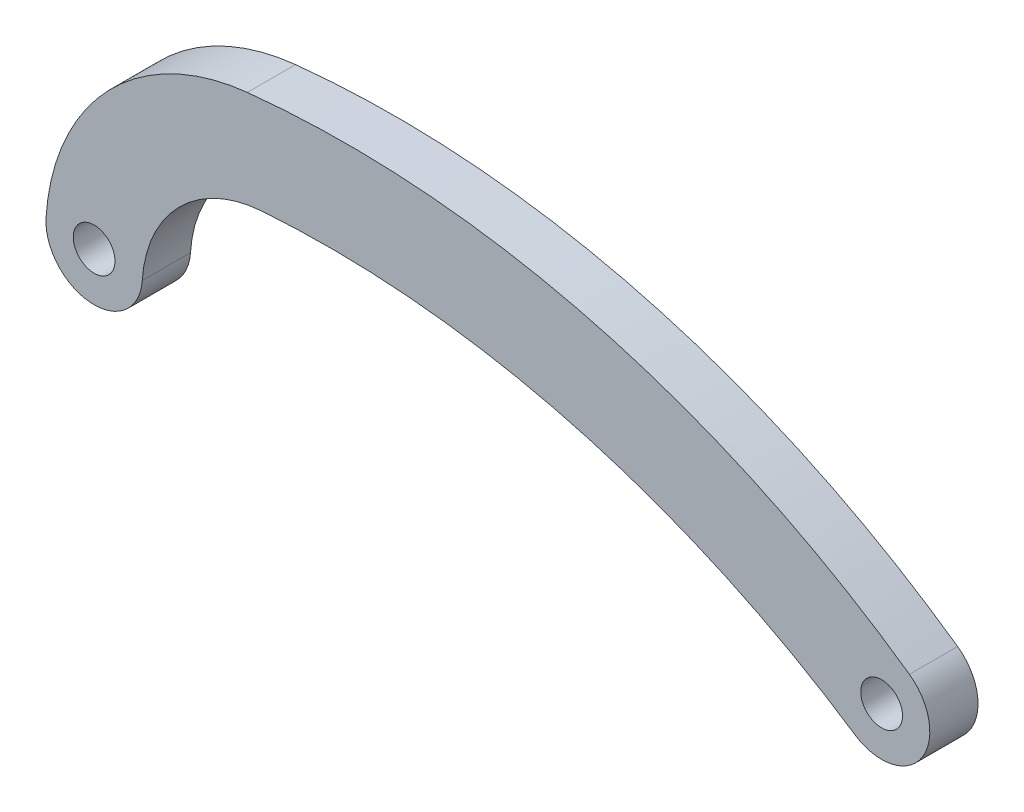
from build123d import *

# Parameters (mm, degrees)
EXTRUDE_1_DEPTH     = 3
SKETCH_2_R          = 1.3
CUT_EXTRUDE_1_DEPTH = 4


with BuildPart() as part:
    # 스케치1 → 보스-돌출1 (new body)
    with BuildSketch(Plane.XY):
        with BuildLine():
            ThreePointArc((5.908095924, 12.125440592), (-2.734946833, 7.908149395), (-6.618010934, -0.890120111))
            ThreePointArc((-6.618010934, -0.890120111), (-3.819295692, -4.078723723), (-0.63069208, -1.280008481))
            ThreePointArc((-0.63069208, -1.280008481), (1.675267899, 3.836644085), (6.775226967, 6.179292672))
            ThreePointArc((6.775226967, 6.179292672), (26.056169451, 4.379851204), (43.709409242, -3.57978808))
            ThreePointArc((43.709409242, -3.57978808), (47.849012899, -2.782847709), (47.104702299, 1.366541899))
            ThreePointArc((47.104702299, 1.366541899), (27.481967947, 10.481515342), (5.908095924, 12.125440592))
        make_face()
    extrude(amount=EXTRUDE_1_DEPTH)

    # 스케치2 → 컷-돌출1 (cut, through all)
    with BuildSketch(Plane.XY.offset(3)):
        with Locations((-3.624351507, -1.085064296)):
            Circle(SKETCH_2_R)
        with Locations((45.375648493, -1.085064296)):
            Circle(SKETCH_2_R)
    extrude(amount=-CUT_EXTRUDE_1_DEPTH, mode=Mode.SUBTRACT)


solid = part.part
